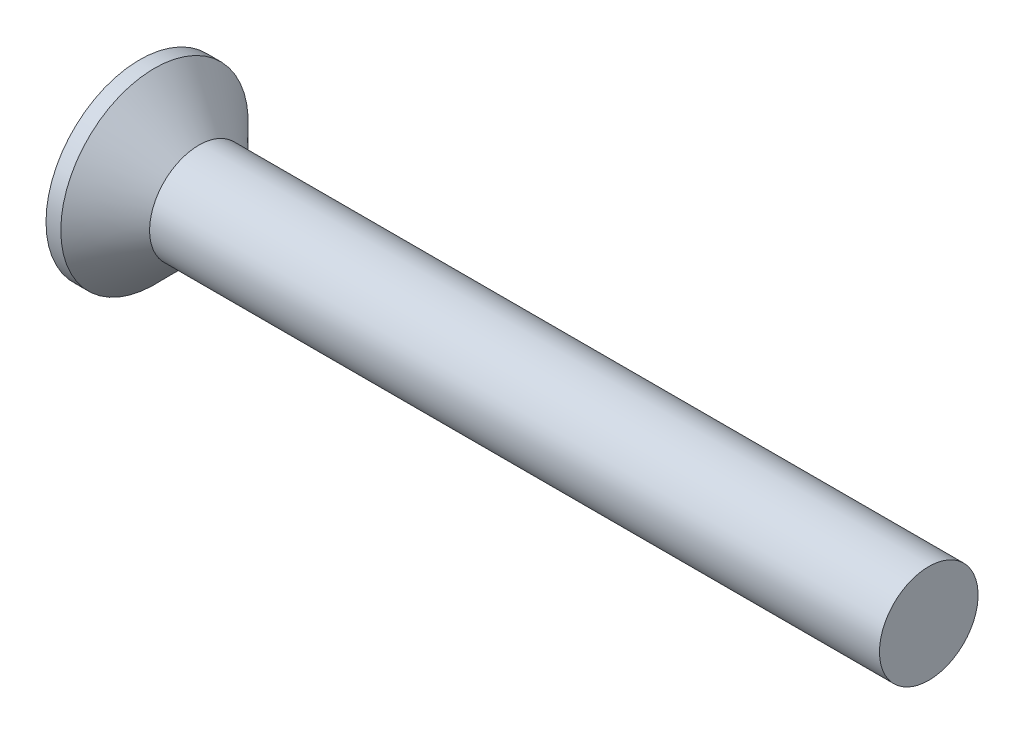
from build123d import *

# Parameters (mm, degrees)
SKETCH3_W         = 0.53
SKETCH3_H         = 2.14
SKETCH4_W         = 0.265
SKETCH4_H         = 0.265
CIRPATTERN1_COUNT = 2
CIRPATTERN1_ANGLE = 90


with BuildPart() as part:
    # BodySke → Base-Revolve (revolve)
    with BuildSketch(Plane.XY):
        Polygon((0, 0), (0, 1.9), (0.3, 1.9), (1.2, 1), (16, 1), (16, 0), align=None)
    revolve(axis=Axis((-6.35, 0, 0), (1, 0, 0)))

    # Sketch3 → Cross section 0
    with BuildSketch(Plane.ZY):
        Rectangle(SKETCH3_W, SKETCH3_H)
    # Sketch4 → Cross section 1
    with BuildSketch(Plane.ZY.offset(-1.54)):
        Rectangle(SKETCH4_W, SKETCH4_H)
    cross = loft(mode=Mode.SUBTRACT)

    # CirPattern1: Cross ×2 about axis
    cirpattern1_axis = Axis((0, 0, 0), (1, 0, 0))
    for i in range(1, CIRPATTERN1_COUNT):
        add(cross.rotate(cirpattern1_axis, i * CIRPATTERN1_ANGLE / (CIRPATTERN1_COUNT - 1)), mode=Mode.SUBTRACT)


solid = part.part
